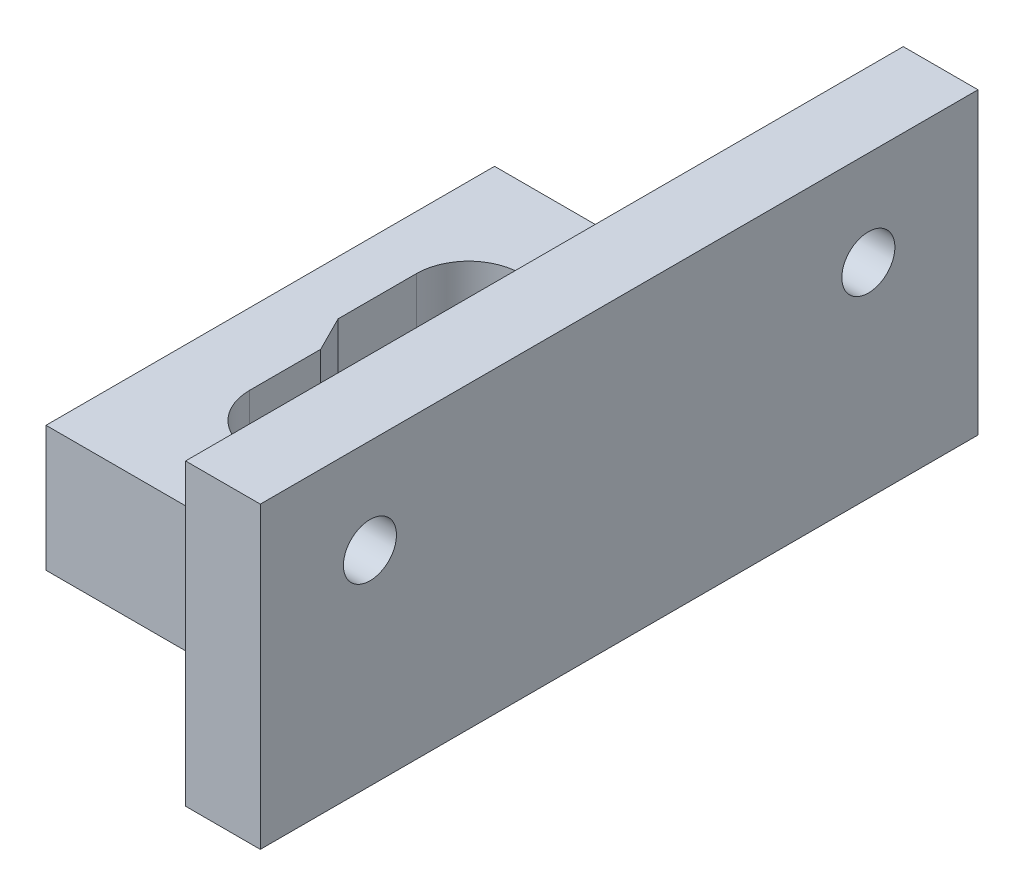
from build123d import *

# Parameters (mm, degrees)
SKETCH1_W                       = 15.24
SKETCH1_H                       = 22.86
BOSS_EXTRUDE2_DEPTH             = 6.4008
CUT_EXTRUDE4_DEPTH              = 1
CUT_EXTRUDE4_DEPTH_BACK         = 7.4008
SKETCH7_W                       = 36.576
SKETCH7_H                       = 15.24
BOSS_EXTRUDE3_DEPTH             = 3.81
F_6_32_TAPPED_HOLE1_D           = 2.7051
F_6_32_TAPPED_HOLE1_CSINK_D     = 4.7752
F_6_32_TAPPED_HOLE1_CSINK_ANGLE = 100


with BuildPart() as part:
    # Sketch1 → Boss-Extrude2 (new body)
    with BuildSketch(Plane(origin=(0, 0, 0), x_dir=(1, 0, 0), z_dir=(0, 1, 0))):
        Rectangle(SKETCH1_W, SKETCH1_H)
        with BuildLine():
            Line((2.208651403, 6.604), (-2.208651403, 6.604))
            ThreePointArc((-2.208651403, 6.604), (-3.555689822, 6.046038418), (-4.113651403, 4.699))
            Line((-4.113651403, 4.699), (-4.113651403, 0.89281026))
            Line((-4.113651403, 0.89281026), (-3.2131, -0.89281026))
            Line((-3.2131, -0.89281026), (-3.2131, -4.699))
            ThreePointArc((-3.2131, -4.699), (-2.655138418, -6.046038418), (-1.3081, -6.604))
            Line((-1.3081, -6.604), (0, -6.604))
            Line((0, -6.604), (1.3081, -6.604))
            ThreePointArc((1.3081, -6.604), (2.655138418, -6.046038418), (3.2131, -4.699))
            Line((3.2131, -4.699), (3.2131, -0.89281026))
            Line((3.2131, -0.89281026), (4.113651403, 0.89281026))
            Line((4.113651403, 0.89281026), (4.113651403, 4.699))
            ThreePointArc((4.113651403, 4.699), (3.555689822, 6.046038418), (2.208651403, 6.604))
        make_face(mode=Mode.SUBTRACT)
    extrude(amount=BOSS_EXTRUDE2_DEPTH)

    # Sketch6 → Cut-Extrude4 (cut, two sides)
    with BuildSketch(Plane(origin=(0, 6.4008, 0), x_dir=(1, 0, 0), z_dir=(0, 1, 0))) as cut_extrude4_sk:
        with BuildLine():
            Line((-3.9751, -1.074087237), (-3.9751, -4.699))
            ThreePointArc((-3.9751, -4.699), (-3.193953785, -6.584853785), (-1.3081, -7.366))
            Line((-1.3081, -7.366), (1.3081, -7.366))
            ThreePointArc((1.3081, -7.366), (3.193953785, -6.584853785), (3.9751, -4.699))
            Line((3.9751, -4.699), (3.9751, -1.074087237))
            Line((3.9751, -1.074087237), (4.875651403, 0.711533282))
            Line((4.875651403, 0.711533282), (4.875651403, 4.699))
            ThreePointArc((4.875651403, 4.699), (4.094505189, 6.584853785), (2.208651403, 7.366))
            Line((2.208651403, 7.366), (-2.208651403, 7.366))
            ThreePointArc((-2.208651403, 7.366), (-4.094505189, 6.584853785), (-4.875651403, 4.699))
            Line((-4.875651403, 4.699), (-4.875651403, 0.711533282))
            Line((-4.875651403, 0.711533282), (-3.9751, -1.074087237))
        make_face()
    extrude(amount=CUT_EXTRUDE4_DEPTH, mode=Mode.SUBTRACT)
    extrude(cut_extrude4_sk.sketch, amount=-CUT_EXTRUDE4_DEPTH_BACK, mode=Mode.SUBTRACT)

    # Sketch7 → Boss-Extrude3 (add)
    with BuildSketch(Plane(origin=(6.35, 0, 0), x_dir=(0, 0, -1), z_dir=(1, 0, 0))):
        with Locations((0, 7.62)):
            Rectangle(SKETCH7_W, SKETCH7_H)
    extrude(amount=BOSS_EXTRUDE3_DEPTH)

    # #6-32 Tapped Hole1 (through all)
    with Locations(Plane.ZY.offset(-6.35)):
        with Locations((12.7, 10.414), (-12.7, 10.414)):
            CounterSinkHole(F_6_32_TAPPED_HOLE1_D / 2, F_6_32_TAPPED_HOLE1_CSINK_D / 2, counter_sink_angle=F_6_32_TAPPED_HOLE1_CSINK_ANGLE)


solid = part.part
